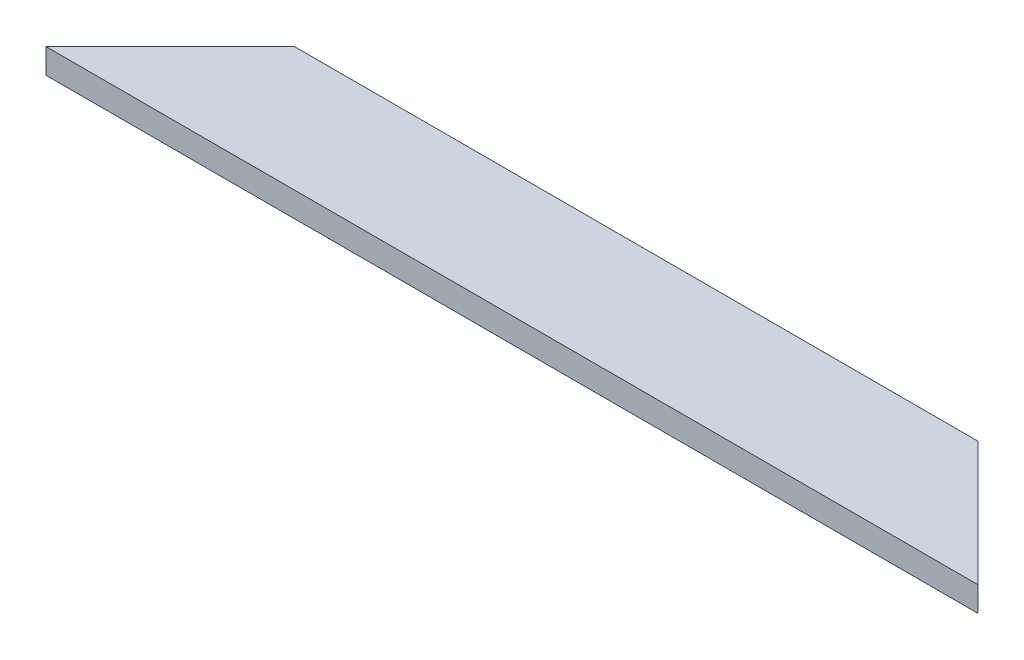
from build123d import *

# Parameters (mm, degrees)
SKETCH_1_W          = 20
SKETCH_1_H          = 4
EXTRUDE_1_DEPTH     = 150
SKETCH_2_OUTSIDE_W  = 182.276
SKETCH_2_OUTSIDE_H  = 52.276
CUT_EXTRUDE_1_DEPTH = 10


with BuildPart() as part:
    # Эскиз1 → Бобышка-Вытянуть1 (new body)
    with BuildSketch(Plane(origin=(0, 0, 0), x_dir=(0, 0, -1), z_dir=(1, 0, 0))):
        with Locations((10, 2)):
            Rectangle(SKETCH_1_W, SKETCH_1_H)
    extrude(amount=EXTRUDE_1_DEPTH)

    # Эскиз2 outside → Вырез-Вытянуть1 (cut)
    with BuildSketch(Plane(origin=(0, 4, 0), x_dir=(1, 0, 0), z_dir=(0, 1, 0))):
        with Locations((75, 10)):
            Rectangle(SKETCH_2_OUTSIDE_W, SKETCH_2_OUTSIDE_H)
        Polygon((150, 0), (130, 20), (20, 20), (0, 0), align=None, mode=Mode.SUBTRACT)
    extrude(amount=-CUT_EXTRUDE_1_DEPTH, mode=Mode.SUBTRACT)


solid = part.part
